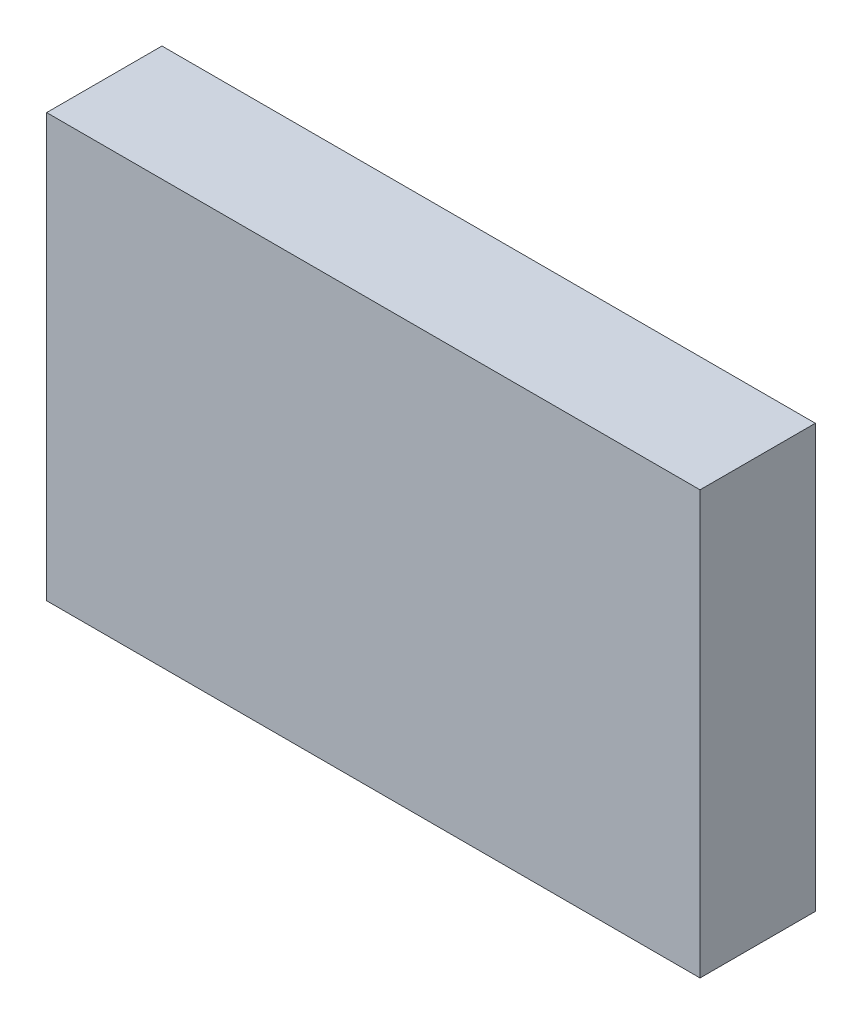
from build123d import *

# Parameters (mm, degrees)
SKETCH1_W           = 85
SKETCH1_H           = 55
BOSS_EXTRUDE1_DEPTH = 15


with BuildPart() as part:
    # Sketch1 → Boss-Extrude1 (new body)
    with BuildSketch(Plane.XY):
        Rectangle(SKETCH1_W, SKETCH1_H)
    extrude(amount=BOSS_EXTRUDE1_DEPTH)


solid = part.part
